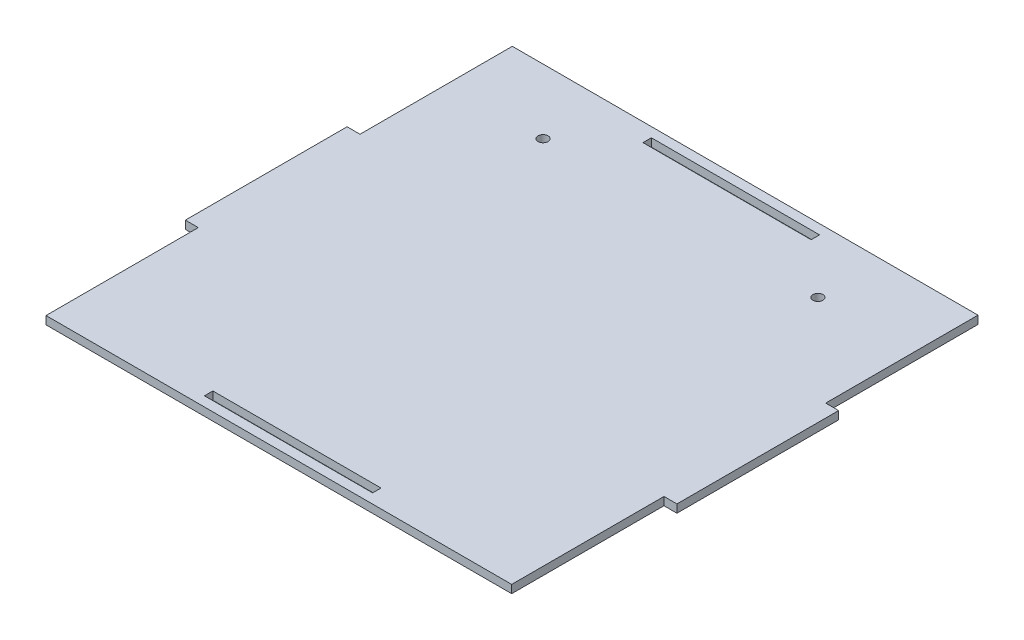
from build123d import *

# Parameters (mm, degrees)
SKETCH1_W           = 52
SKETCH1_H           = 2.6
BOSS_EXTRUDE1_DEPTH = 2.5
SKETCH2_R           = 1.55
CUT_EXTRUDE1_DEPTH  = 10


with BuildPart() as part:
    # Sketch1 → Boss-Extrude1 (new body)
    with BuildSketch(Plane(origin=(0, 0, 0), x_dir=(1, 0, 0), z_dir=(0, 1, 0))):
        Polygon((72, -25), (76, -25), (76, 25), (72, 25), (72, 72.1), (-72, 72.1), (-72, 25), (-76, 25), (-76, -25), (-72, -25), (-72, -72.1), (72, -72.1), align=None)
        with Locations((0, -67.8)):
            Rectangle(SKETCH1_W, SKETCH1_H, mode=Mode.SUBTRACT)
        with Locations((0, 67.8)):
            Rectangle(SKETCH1_W, SKETCH1_H, mode=Mode.SUBTRACT)
    extrude(amount=BOSS_EXTRUDE1_DEPTH)

    # Sketch2 → Cut-Extrude1 (cut)
    with BuildSketch(Plane(origin=(0, 2.5, 0), x_dir=(1, 0, 0), z_dir=(0, 1, 0))):
        with Locations((-42.5, 52.1)):
            Circle(SKETCH2_R)
        with Locations((42.5, 52.1)):
            Circle(SKETCH2_R)
    extrude(amount=-CUT_EXTRUDE1_DEPTH, mode=Mode.SUBTRACT)


solid = part.part
